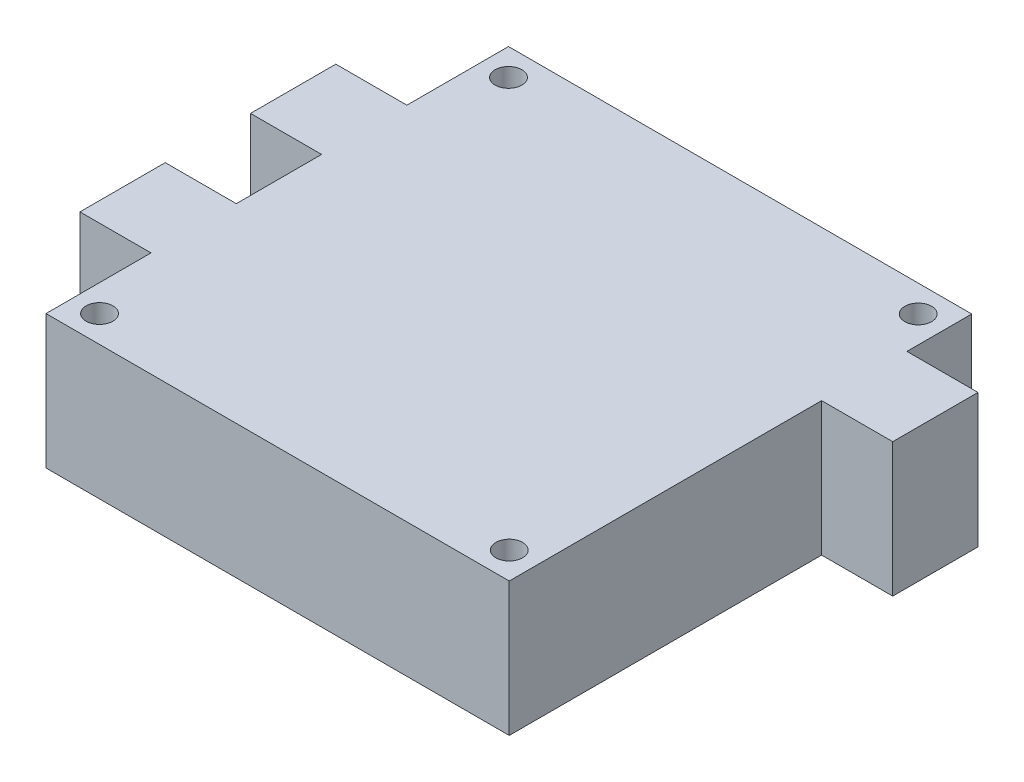
from build123d import *

# Parameters (mm, degrees)
SKETCH1_R           = 1.6
BOSS_EXTRUDE1_DEPTH = 16


with BuildPart() as part:
    # Sketch1 → Boss-Extrude1 (new body)
    with BuildSketch(Plane(origin=(0, 0, 0), x_dir=(1, 0, 0), z_dir=(0, 1, 0))):
        Polygon((-27.7, 27.655), (27.7, 27.655), (27.7, 19.905), (36.2, 19.905), (36.2, 9.705), (27.7, 9.705), (27.7, -27.655), (-27.7, -27.655), (-27.7, -15.095), (-36.2, -15.095), (-36.2, -4.895), (-27.7, -4.895), (-27.7, 5.305), (-36.2, 5.305), (-36.2, 15.505), (-27.7, 15.505), align=None)
        with Locations((-24.5, 24.455)):
            Circle(SKETCH1_R, mode=Mode.SUBTRACT)
        with Locations((24.5, 24.455)):
            Circle(SKETCH1_R, mode=Mode.SUBTRACT)
        with Locations((-24.5, -24.455)):
            Circle(SKETCH1_R, mode=Mode.SUBTRACT)
        with Locations((24.5, -24.455)):
            Circle(SKETCH1_R, mode=Mode.SUBTRACT)
    extrude(amount=BOSS_EXTRUDE1_DEPTH)


solid = part.part
